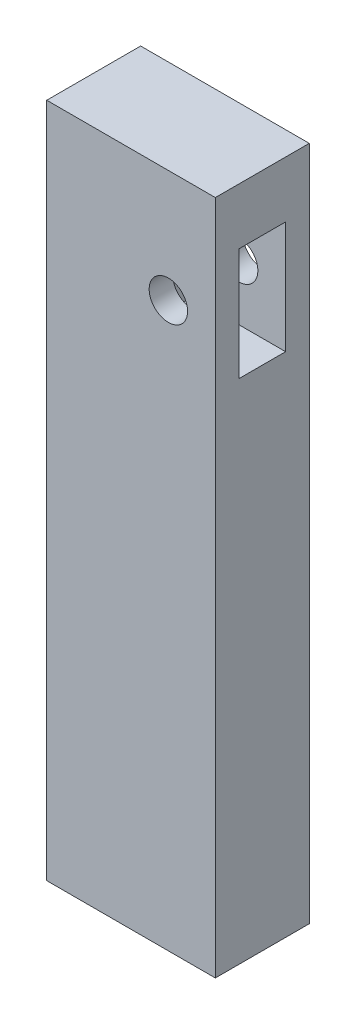
from build123d import *

# Parameters (mm, degrees)
SKETCH3_W           = 228
SKETCH3_H           = 914
BOSS_EXTRUDE2_DEPTH = 127
SKETCH4_W           = 63
SKETCH4_H           = 152
CUT_EXTRUDE1_DEPTH  = 127
SKETCH6_R           = 26
CUT_EXTRUDE2_DEPTH  = 127


with BuildPart() as part:
    # Sketch3 → Boss-Extrude2 (new body)
    with BuildSketch(Plane.XY):
        Rectangle(SKETCH3_W, SKETCH3_H)
    extrude(amount=BOSS_EXTRUDE2_DEPTH)

    # Sketch4 → Cut-Extrude1 (cut)
    with BuildSketch(Plane(origin=(114, 0, 0), x_dir=(0, 0, -1), z_dir=(1, 0, 0))):
        with Locations((-63.5, 305)):
            Rectangle(SKETCH4_W, SKETCH4_H)
    extrude(amount=-CUT_EXTRUDE1_DEPTH, mode=Mode.SUBTRACT)

    # Sketch6 → Cut-Extrude2 (cut)
    with BuildSketch(Plane.XY):
        with Locations((50.5, 305)):
            Circle(SKETCH6_R)
    extrude(amount=CUT_EXTRUDE2_DEPTH, mode=Mode.SUBTRACT)


solid = part.part
